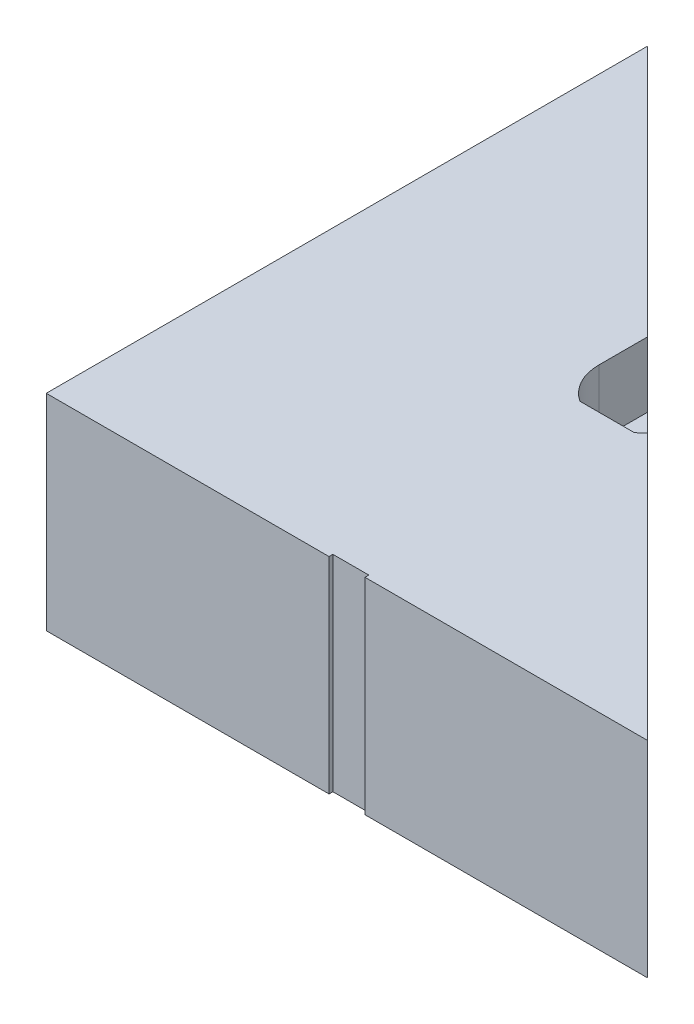
from build123d import *

# Parameters (mm, degrees)
SKETCH1_W           = 117
SKETCH1_H           = 117
BOSS_EXTRUDE1_DEPTH = 40
SKETCH2_W           = 10.53028371
SKETCH2_H           = 7.9375
CUT_EXTRUDE1_DEPTH  = 12.7
SKETCH7_W           = 7
SKETCH7_H           = 1.5
CUT_EXTRUDE5_DEPTH  = 171.22925718
CIRPATTERN3_COUNT   = 3
CIRPATTERN3_ANGLE   = 180
CUT_EXTRUDE11_DEPTH = 171.22925718


with BuildPart() as part:
    # Sketch1 → Boss-Extrude1 (new body)
    with BuildSketch(Plane(origin=(0, 0, 0), x_dir=(1, 0, 0), z_dir=(0, 1, 0))):
        with Locations((58.5, 58.5)):
            Rectangle(SKETCH1_W, SKETCH1_H)
    extrude(amount=BOSS_EXTRUDE1_DEPTH)

    # Sketch2 → Cut-Extrude1 (cut)
    with BuildSketch(Plane(origin=(0, 40, 0), x_dir=(1, 0, 0), z_dir=(0, 1, 0))):
        with BuildLine():
            ThreePointArc((63.765141855, 66.4375), (66.892737967, 63.004173), (68.025, 58.5))
            Line((68.025, 58.5), (68.025, 74.375))
            Line((68.025, 74.375), (48.975, 74.375))
            Line((48.975, 74.375), (48.975, 58.5))
            ThreePointArc((48.975, 58.5), (50.107262033, 63.004173), (53.234858145, 66.4375))
            ThreePointArc((53.234858145, 66.4375), (58.5, 68.025), (63.765141855, 66.4375))
        make_face()
        with BuildLine():
            ThreePointArc((63.765141855, 50.5625), (66.892737967, 53.995827), (68.025, 58.5))
            Line((68.025, 58.5), (63.765141855, 58.5))
            Line((63.765141855, 58.5), (63.765141855, 50.5625))
        make_face()
        with BuildLine():
            Line((63.765141855, 58.5), (68.025, 58.5))
            ThreePointArc((68.025, 58.5), (66.892737967, 63.004173), (63.765141855, 66.4375))
            Line((63.765141855, 66.4375), (63.765141855, 58.5))
        make_face()
        with BuildLine():
            Line((53.234858145, 50.5625), (53.234858145, 58.5))
            Line((53.234858145, 58.5), (48.975, 58.5))
            ThreePointArc((48.975, 58.5), (50.107262033, 53.995827), (53.234858145, 50.5625))
        make_face()
        with BuildLine():
            Line((48.975, 58.5), (53.234858145, 58.5))
            Line((53.234858145, 58.5), (53.234858145, 66.4375))
            ThreePointArc((53.234858145, 66.4375), (50.107262033, 63.004173), (48.975, 58.5))
        make_face()
        with Locations((58.5, 62.46875)):
            Rectangle(SKETCH2_W, SKETCH2_H)
        with BuildLine():
            Line((53.234858145, 66.4375), (63.765141855, 66.4375))
            ThreePointArc((63.765141855, 66.4375), (58.5, 68.025), (53.234858145, 66.4375))
        make_face()
        with BuildLine():
            ThreePointArc((63.765141855, 50.5625), (66.892737967, 53.995827), (68.025, 58.5))
            Line((68.025, 58.5), (63.765141855, 58.5))
            Line((63.765141855, 58.5), (63.765141855, 50.5625))
        make_face()
        with BuildLine():
            Line((63.765141855, 58.5), (68.025, 58.5))
            ThreePointArc((68.025, 58.5), (66.892737967, 63.004173), (63.765141855, 66.4375))
            Line((63.765141855, 66.4375), (63.765141855, 58.5))
        make_face()
        with BuildLine():
            Line((53.234858145, 50.5625), (53.234858145, 58.5))
            Line((53.234858145, 58.5), (48.975, 58.5))
            ThreePointArc((48.975, 58.5), (50.107262033, 53.995827), (53.234858145, 50.5625))
        make_face()
        with BuildLine():
            Line((48.975, 58.5), (53.234858145, 58.5))
            Line((53.234858145, 58.5), (53.234858145, 66.4375))
            ThreePointArc((53.234858145, 66.4375), (50.107262033, 63.004173), (48.975, 58.5))
        make_face()
        with Locations((58.5, 54.53125)):
            Rectangle(SKETCH2_W, SKETCH2_H)
    extrude(amount=-CUT_EXTRUDE1_DEPTH, mode=Mode.SUBTRACT)

    # Sketch7 → Cut-Extrude5 (cut, through all)
    with BuildSketch(Plane.XZ):
        with Locations((58.5, -117)):
            Rectangle(SKETCH7_W, SKETCH7_H)
    cut_extrude5 = extrude(amount=-CUT_EXTRUDE5_DEPTH, mode=Mode.SUBTRACT)

    # CirPattern3: Cut-Extrude5 ×3 about axis
    cirpattern3_axis = Axis((58.5, 0, -58.5), (0, -1, 0))
    for i in range(1, CIRPATTERN3_COUNT):
        add(cut_extrude5.rotate(cirpattern3_axis, i * CIRPATTERN3_ANGLE / (CIRPATTERN3_COUNT - 1)), mode=Mode.SUBTRACT)

    # Sketch11 → Cut-Extrude11 (cut, through all)
    with BuildSketch(Plane.XZ):
        Polygon((0, -117), (117, 0), (188.640274668, -71.640274668), (71.640274668, -188.640274668), align=None)
    extrude(amount=-CUT_EXTRUDE11_DEPTH, mode=Mode.SUBTRACT)


solid = part.part
